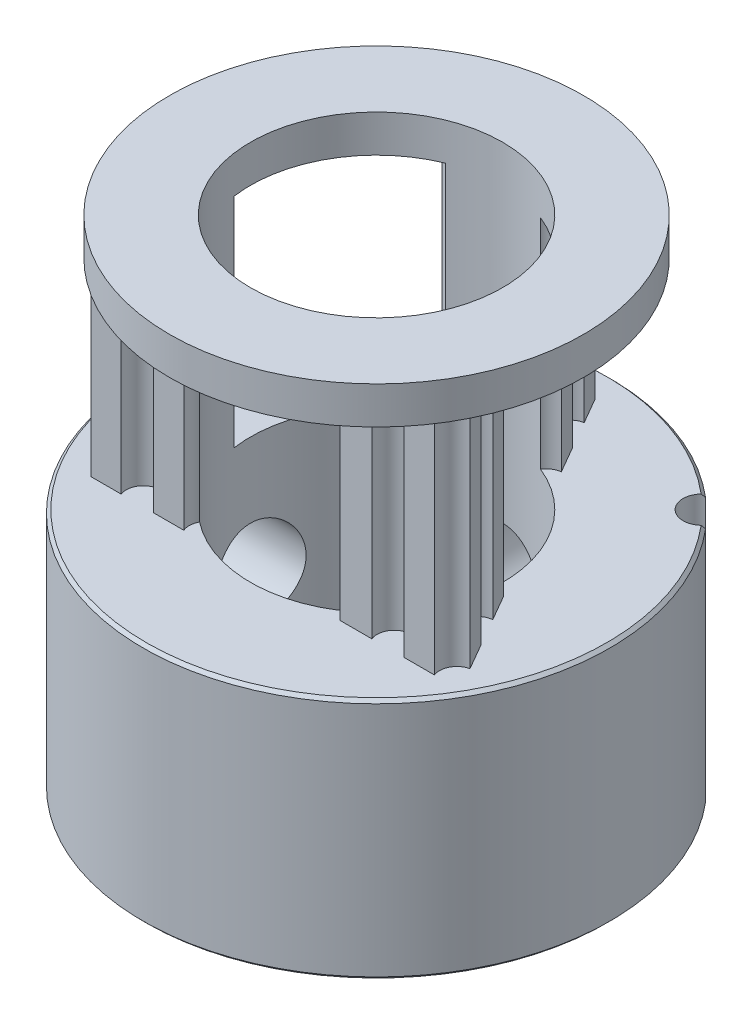
from build123d import *

# Parameters (mm, degrees)
P_IDAT_START            = 7.8
SKICA1_R                = 2.5
P_IDAT_VYSUNUT_M1_DEPTH = 7
SKICA2_R                = 3.5
SKICA2_R_2              = 2.5
P_IDAT_VYSUNUT_M2_DEPTH = 7.8
SKICA3_R                = 3.5
SKICA3_R_2              = 2.5
P_IDAT_VYSUNUT_M3_DEPTH = 1.2
SKICA5_R                = 7.5
SKICA5_R_2              = 3.5
P_IDAT_VYSUNUT_M4_DEPTH = 1.2
SKICA6_R                = 7.5
SKICA6_R_2              = 3.5
P_IDAT_VYSUNUT_M5_DEPTH = 7.8
ZKOSEN_1_SIZE           = 0.1
ZKOSEN_2_SIZE           = 0.1
ZKOSEN_3_SIZE           = 0.1
SKETCH8_OUTSIDE_W       = 22.314
SKETCH8_OUTSIDE_H       = 22.314
SKETCH8_OUTSIDE_R       = 6.65
CUT_EXTRUDE2_DEPTH      = 5
SKETCH19_R              = 1.5
CUT_EXTRUDE6_DEPTH      = 5
SKETCH20_R              = 1.5
CUT_EXTRUDE7_DEPTH      = 5
SKETCH7_R               = 4.05
CUT_EXTRUDE9_DEPTH      = 20
SKETCH27_R              = 7.4
CUT_EXTRUDE12_DEPTH     = 7
BOSS_EXTRUDE2_DEPTH     = 7.1
SKETCH28_R              = 4.05
CUT_EXTRUDE13_DEPTH     = 30
SKETCH30_R              = 0.617994848
CUT_EXTRUDE15_DEPTH     = 30


with BuildPart() as part:
    # Skica1 → Přidat vysunutím1 (new body)
    with BuildSketch(Plane(origin=(0, 0, 0), x_dir=(1, 0, 0), z_dir=(0, 1, 0)).offset(P_IDAT_START)):
        with BuildLine():
            ThreePointArc((-5.730143195, 1.098270155), (-5.09645097, 1.530497044), (-5.387174672, 2.240331989))
            ThreePointArc((-5.387174672, 2.240331989), (-5.468060657, 2.292707421), (-5.540463547, 2.356296335))
            ThreePointArc((-5.540463547, 2.356296335), (-5.573874331, 2.399596558), (-5.596043873, 2.44959357))
            ThreePointArc((-5.596043873, 2.44959357), (-5.50369925, 2.650567912), (-5.404139771, 2.848067596))
            ThreePointArc((-5.404139771, 2.848067596), (-5.351227535, 2.86190541), (-5.296542742, 2.862779021))
            ThreePointArc((-5.296542742, 2.862779021), (-5.201685094, 2.845815675), (-5.110305882, 2.815228615))
            ThreePointArc((-5.110305882, 2.815228615), (-4.374063308, 3.030479148), (-4.431206919, 3.795410862))
            ThreePointArc((-4.431206919, 3.795410862), (-4.491949163, 3.870218002), (-4.541158349, 3.953068377))
            ThreePointArc((-4.541158349, 3.953068377), (-4.559553388, 4.004573836), (-4.565187949, 4.058974585))
            ThreePointArc((-4.565187949, 4.058974585), (-4.415258506, 4.221576484), (-4.259541056, 4.378644275))
            ThreePointArc((-4.259541056, 4.378644275), (-4.204942409, 4.375454038), (-4.15266412, 4.359386362))
            ThreePointArc((-4.15266412, 4.359386362), (-4.067691098, 4.313940635), (-3.990236225, 4.256612884))
            ThreePointArc((-3.990236225, 4.256612884), (-3.223511854, 4.233816838), (-3.041481758, 4.978968476))
            ThreePointArc((-3.041481758, 4.978968476), (-3.076134388, 5.06888468), (-3.097332931, 5.162886543))
            ThreePointArc((-3.097332931, 5.162886543), (-3.09891159, 5.217555525), (-3.08745962, 5.271034888))
            ThreePointArc((-3.08745962, 5.271034888), (-2.894621497, 5.379347737), (-2.697988784, 5.480608745))
            ThreePointArc((-2.697988784, 5.480608745), (-2.647048223, 5.460702739), (-2.6022938, 5.429266591))
            ThreePointArc((-2.6022938, 5.429266591), (-2.535523156, 5.359787029), (-2.479574443, 5.281330225))
            ThreePointArc((-2.479574443, 5.281330225), (-1.7574206, 5.022719037), (-1.354035171, 5.675149965))
            ThreePointArc((-1.354035171, 5.675149965), (-1.359206146, 5.771373608), (-1.350318985, 5.867325402))
            ThreePointArc((-1.350318985, 5.867325402), (-1.334926735, 5.919806527), (-1.307509232, 5.967129569))
            ThreePointArc((-1.307509232, 5.967129569), (-1.090638767, 6.010550954), (-0.872338572, 6.046093045))
            ThreePointArc((-0.872338572, 6.046093045), (-0.830042514, 6.01141981), (-0.797192832, 5.967692379))
            ThreePointArc((-0.797192832, 5.967692379), (-0.755160541, 5.880980125), (-0.726194639, 5.789074167))
            ThreePointArc((-0.726194639, 5.789074167), (-0.119300773, 5.319962501), (0.465953812, 5.815808234))
            ThreePointArc((0.465953812, 5.815808234), (0.490770664, 5.908920276), (0.528873591, 5.997429571))
            ThreePointArc((0.528873591, 5.997429571), (0.55973005, 6.04258562), (0.600429269, 6.079120034))
            ThreePointArc((0.600429269, 6.079120034), (0.820103284, 6.053399565), (1.038702217, 6.019743632))
            ThreePointArc((1.038702217, 6.019743632), (1.06821354, 5.973697225), (1.085942924, 5.921958857))
            ThreePointArc((1.085942924, 5.921958857), (1.099122448, 5.826501911), (1.098270155, 5.730143195))
            ThreePointArc((1.098270155, 5.730143195), (1.530497044, 5.09645097), (2.240331989, 5.387174672))
            ThreePointArc((2.240331989, 5.387174672), (2.292707421, 5.468060657), (2.356296335, 5.540463547))
            ThreePointArc((2.356296335, 5.540463547), (2.399596558, 5.573874331), (2.44959357, 5.596043873))
            ThreePointArc((2.44959357, 5.596043873), (2.650567912, 5.50369925), (2.848067596, 5.404139771))
            ThreePointArc((2.848067596, 5.404139771), (2.86190541, 5.351227535), (2.862779021, 5.296542742))
            ThreePointArc((2.862779021, 5.296542742), (2.845815675, 5.201685094), (2.815228615, 5.110305882))
            ThreePointArc((2.815228615, 5.110305882), (3.030479148, 4.374063308), (3.795410862, 4.431206919))
            ThreePointArc((3.795410862, 4.431206919), (3.870218002, 4.491949163), (3.953068377, 4.541158349))
            ThreePointArc((3.953068377, 4.541158349), (4.004573836, 4.559553388), (4.058974585, 4.565187949))
            ThreePointArc((4.058974585, 4.565187949), (4.221576484, 4.415258506), (4.378644275, 4.259541056))
            ThreePointArc((4.378644275, 4.259541056), (4.375454038, 4.204942409), (4.359386362, 4.15266412))
            ThreePointArc((4.359386362, 4.15266412), (4.313940635, 4.067691098), (4.256612884, 3.990236225))
            ThreePointArc((4.256612884, 3.990236225), (4.233816838, 3.223511854), (4.978968476, 3.041481758))
            ThreePointArc((4.978968476, 3.041481758), (5.06888468, 3.076134388), (5.162886543, 3.097332931))
            ThreePointArc((5.162886543, 3.097332931), (5.217555525, 3.09891159), (5.271034888, 3.08745962))
            ThreePointArc((5.271034888, 3.08745962), (5.379347737, 2.894621497), (5.480608745, 2.697988784))
            ThreePointArc((5.480608745, 2.697988784), (5.460702739, 2.647048223), (5.429266591, 2.6022938))
            ThreePointArc((5.429266591, 2.6022938), (5.359787029, 2.535523156), (5.281330225, 2.479574443))
            ThreePointArc((5.281330225, 2.479574443), (5.022719037, 1.7574206), (5.675149965, 1.354035171))
            ThreePointArc((5.675149965, 1.354035171), (5.771373608, 1.359206146), (5.867325402, 1.350318985))
            ThreePointArc((5.867325402, 1.350318985), (5.919806527, 1.334926735), (5.967129569, 1.307509232))
            ThreePointArc((5.967129569, 1.307509232), (6.010550954, 1.090638767), (6.046093045, 0.872338572))
            ThreePointArc((6.046093045, 0.872338572), (6.01141981, 0.830042514), (5.967692379, 0.797192832))
            ThreePointArc((5.967692379, 0.797192832), (5.880980125, 0.755160541), (5.789074167, 0.726194639))
            ThreePointArc((5.789074167, 0.726194639), (5.319962501, 0.119300773), (5.815808234, -0.465953812))
            ThreePointArc((5.815808234, -0.465953812), (5.908920276, -0.490770664), (5.997429571, -0.528873591))
            ThreePointArc((5.997429571, -0.528873591), (6.04258562, -0.55973005), (6.079120034, -0.600429269))
            ThreePointArc((6.079120034, -0.600429269), (6.053399565, -0.820103284), (6.019743632, -1.038702217))
            ThreePointArc((6.019743632, -1.038702217), (5.973697225, -1.06821354), (5.921958857, -1.085942924))
            ThreePointArc((5.921958857, -1.085942924), (5.826501911, -1.099122448), (5.730143195, -1.098270155))
            ThreePointArc((5.730143195, -1.098270155), (5.09645097, -1.530497044), (5.387174672, -2.240331989))
            ThreePointArc((5.387174672, -2.240331989), (5.468060657, -2.292707421), (5.540463547, -2.356296335))
            ThreePointArc((5.540463547, -2.356296335), (5.573874331, -2.399596558), (5.596043873, -2.44959357))
            ThreePointArc((5.596043873, -2.44959357), (5.50369925, -2.650567911), (5.404139771, -2.848067596))
            ThreePointArc((5.404139771, -2.848067596), (5.351227535, -2.86190541), (5.296542742, -2.862779021))
            ThreePointArc((5.296542742, -2.862779021), (5.201685094, -2.845815675), (5.110305882, -2.815228615))
            ThreePointArc((5.110305882, -2.815228615), (4.374063308, -3.030479148), (4.431206919, -3.795410862))
            ThreePointArc((4.431206919, -3.795410862), (4.491949163, -3.870218002), (4.541158349, -3.953068377))
            ThreePointArc((4.541158349, -3.953068377), (4.559553388, -4.004573836), (4.565187949, -4.058974585))
            ThreePointArc((4.565187949, -4.058974585), (4.415258506, -4.221576484), (4.259541056, -4.378644275))
            ThreePointArc((4.259541056, -4.378644275), (4.204942409, -4.375454038), (4.15266412, -4.359386362))
            ThreePointArc((4.15266412, -4.359386362), (4.067691098, -4.313940635), (3.990236225, -4.256612884))
            ThreePointArc((3.990236225, -4.256612884), (3.223511854, -4.233816838), (3.041481758, -4.978968476))
            ThreePointArc((3.041481758, -4.978968476), (3.076134388, -5.06888468), (3.097332931, -5.162886543))
            ThreePointArc((3.097332931, -5.162886543), (3.09891159, -5.217555525), (3.08745962, -5.271034888))
            ThreePointArc((3.08745962, -5.271034888), (2.894621497, -5.379347737), (2.697988784, -5.480608745))
            ThreePointArc((2.697988784, -5.480608745), (2.647048223, -5.460702739), (2.6022938, -5.429266591))
            ThreePointArc((2.6022938, -5.429266591), (2.535523156, -5.359787029), (2.479574443, -5.281330225))
            ThreePointArc((2.479574443, -5.281330225), (1.7574206, -5.022719037), (1.354035171, -5.675149965))
            ThreePointArc((1.354035171, -5.675149965), (1.359206146, -5.771373608), (1.350318985, -5.867325402))
            ThreePointArc((1.350318985, -5.867325402), (1.334926735, -5.919806527), (1.307509232, -5.967129569))
            ThreePointArc((1.307509232, -5.967129569), (1.090638767, -6.010550954), (0.872338572, -6.046093045))
            ThreePointArc((0.872338572, -6.046093045), (0.830042514, -6.01141981), (0.797192832, -5.967692379))
            ThreePointArc((0.797192832, -5.967692379), (0.755160541, -5.880980125), (0.726194639, -5.789074167))
            ThreePointArc((0.726194639, -5.789074167), (0.119300773, -5.319962501), (-0.465953812, -5.815808234))
            ThreePointArc((-0.465953812, -5.815808234), (-0.490770664, -5.908920276), (-0.528873591, -5.997429571))
            ThreePointArc((-0.528873591, -5.997429571), (-0.55973005, -6.04258562), (-0.600429269, -6.079120034))
            ThreePointArc((-0.600429269, -6.079120034), (-0.820103284, -6.053399565), (-1.038702217, -6.019743632))
            ThreePointArc((-1.038702217, -6.019743632), (-1.06821354, -5.973697225), (-1.085942924, -5.921958857))
            ThreePointArc((-1.085942924, -5.921958857), (-1.099122448, -5.826501911), (-1.098270155, -5.730143195))
            ThreePointArc((-1.098270155, -5.730143195), (-1.530497044, -5.09645097), (-2.240331989, -5.387174672))
            ThreePointArc((-2.240331989, -5.387174672), (-2.292707421, -5.468060657), (-2.356296335, -5.540463547))
            ThreePointArc((-2.356296335, -5.540463547), (-2.399596558, -5.573874331), (-2.44959357, -5.596043873))
            ThreePointArc((-2.44959357, -5.596043873), (-2.650567912, -5.50369925), (-2.848067596, -5.404139771))
            ThreePointArc((-2.848067596, -5.404139771), (-2.86190541, -5.351227535), (-2.862779021, -5.296542742))
            ThreePointArc((-2.862779021, -5.296542742), (-2.845815675, -5.201685094), (-2.815228615, -5.110305882))
            ThreePointArc((-2.815228615, -5.110305882), (-3.030479148, -4.374063308), (-3.795410862, -4.431206919))
            ThreePointArc((-3.795410862, -4.431206919), (-3.870218002, -4.491949163), (-3.953068377, -4.541158349))
            ThreePointArc((-3.953068377, -4.541158349), (-4.004573836, -4.559553388), (-4.058974585, -4.565187949))
            ThreePointArc((-4.058974585, -4.565187949), (-4.221576484, -4.415258506), (-4.378644275, -4.259541056))
            ThreePointArc((-4.378644275, -4.259541056), (-4.375454038, -4.204942409), (-4.359386362, -4.15266412))
            ThreePointArc((-4.359386362, -4.15266412), (-4.313940635, -4.067691098), (-4.256612884, -3.990236225))
            ThreePointArc((-4.256612884, -3.990236225), (-4.233816838, -3.223511854), (-4.978968476, -3.041481758))
            ThreePointArc((-4.978968476, -3.041481758), (-5.06888468, -3.076134388), (-5.162886543, -3.097332931))
            ThreePointArc((-5.162886543, -3.097332931), (-5.217555525, -3.09891159), (-5.271034888, -3.08745962))
            ThreePointArc((-5.271034888, -3.08745962), (-5.379347737, -2.894621497), (-5.480608745, -2.697988784))
            ThreePointArc((-5.480608745, -2.697988784), (-5.460702739, -2.647048223), (-5.429266591, -2.6022938))
            ThreePointArc((-5.429266591, -2.6022938), (-5.359787029, -2.535523156), (-5.281330225, -2.479574443))
            ThreePointArc((-5.281330225, -2.479574443), (-5.022719037, -1.7574206), (-5.675149965, -1.354035171))
            ThreePointArc((-5.675149965, -1.354035171), (-5.771373608, -1.359206146), (-5.867325402, -1.350318985))
            ThreePointArc((-5.867325402, -1.350318985), (-5.919806527, -1.334926735), (-5.967129569, -1.307509232))
            ThreePointArc((-5.967129569, -1.307509232), (-6.010550954, -1.090638767), (-6.046093045, -0.872338572))
            ThreePointArc((-6.046093045, -0.872338572), (-6.01141981, -0.830042514), (-5.967692379, -0.797192832))
            ThreePointArc((-5.967692379, -0.797192832), (-5.880980125, -0.755160541), (-5.789074167, -0.726194639))
            ThreePointArc((-5.789074167, -0.726194639), (-5.319962501, -0.119300773), (-5.815808234, 0.465953812))
            ThreePointArc((-5.815808234, 0.465953812), (-5.908920276, 0.490770664), (-5.997429571, 0.528873591))
            ThreePointArc((-5.997429571, 0.528873591), (-6.04258562, 0.55973005), (-6.079120034, 0.600429269))
            ThreePointArc((-6.079120034, 0.600429269), (-6.053399565, 0.820103284), (-6.019743632, 1.038702217))
            ThreePointArc((-6.019743632, 1.038702217), (-5.973697225, 1.06821354), (-5.921958857, 1.085942924))
            ThreePointArc((-5.921958857, 1.085942924), (-5.826501911, 1.099122448), (-5.730143195, 1.098270155))
        make_face()
        Circle(SKICA1_R, mode=Mode.SUBTRACT)
    extrude(amount=P_IDAT_VYSUNUT_M1_DEPTH)

    # Skica2 → Přidat vysunutím2 (add)
    with BuildSketch(Plane.XZ.offset(-7.8)):
        Circle(SKICA2_R)
        Circle(SKICA2_R_2, mode=Mode.SUBTRACT)
    extrude(amount=P_IDAT_VYSUNUT_M2_DEPTH)

    # Skica3 → Přidat vysunutím3 (add)
    with BuildSketch(Plane(origin=(0, 14.8, 0), x_dir=(1, 0, 0), z_dir=(0, 1, 0))):
        Circle(SKICA3_R)
        Circle(SKICA3_R_2, mode=Mode.SUBTRACT)
    extrude(amount=P_IDAT_VYSUNUT_M3_DEPTH)

    # Zkosení2
    zkosen_2_edges = [part.edges().sort_by_distance(p)[0] for p in [
        (-2.5, 0, 0),
        (-2.5, 16, 0),
    ]]
    chamfer(zkosen_2_edges, length=ZKOSEN_2_SIZE)


with BuildPart() as body_2:
    # Skica5 → Přidat vysunutím4 (new body)
    with BuildSketch(Plane(origin=(0, 16, 0), x_dir=(1, 0, 0), z_dir=(0, 1, 0))):
        Circle(SKICA5_R)
        Circle(SKICA5_R_2, mode=Mode.SUBTRACT)
    extrude(amount=-P_IDAT_VYSUNUT_M4_DEPTH)

    # Zkosení1
    zkosen_1_edges = [body_2.edges().sort_by_distance(p)[0] for p in [
        (-7.5, 16, 0),
        (-7.5, 14.8, 0),
    ]]
    chamfer(zkosen_1_edges, length=ZKOSEN_1_SIZE)

    # Sketch8 outside → Cut-Extrude2 (cut)
    with BuildSketch(Plane(origin=(0, 16, 0), x_dir=(1, 0, 0), z_dir=(0, 1, 0))):
        Rectangle(SKETCH8_OUTSIDE_W, SKETCH8_OUTSIDE_H)
        Circle(SKETCH8_OUTSIDE_R, mode=Mode.SUBTRACT)
    extrude(amount=-CUT_EXTRUDE2_DEPTH, mode=Mode.SUBTRACT)


with BuildPart() as body_3:
    # Skica6 → Přidat vysunutím5 (new body)
    with BuildSketch(Plane.XZ):
        Circle(SKICA6_R)
        Circle(SKICA6_R_2, mode=Mode.SUBTRACT)
    extrude(amount=-P_IDAT_VYSUNUT_M5_DEPTH)

    # Zkosení3
    zkosen_3_edges = [body_3.edges().sort_by_distance(p)[0] for p in [
        (-7.5, 0, 0),
        (-7.5, 7.8, 0),
    ]]
    chamfer(zkosen_3_edges, length=ZKOSEN_3_SIZE)

    # Sketch19 → Cut-Extrude6 (cut)
    with BuildSketch(Plane(origin=(0, 0, -7.5), x_dir=(-1, 0, 0), z_dir=(0, 0, -1))):
        with Locations((0, 3.9)):
            Circle(SKETCH19_R)
    extrude(amount=-CUT_EXTRUDE6_DEPTH, mode=Mode.SUBTRACT)

    # Sketch20 → Cut-Extrude7 (cut)
    with BuildSketch(Plane.ZY.offset(7.5)):
        with Locations((0, 3.9)):
            Circle(SKETCH20_R)
    extrude(amount=-CUT_EXTRUDE7_DEPTH, mode=Mode.SUBTRACT)


with BuildPart() as cut_extrude9_tool:
    # Sketch7 → Cut-Extrude9 (new body)
    with BuildSketch(Plane.XZ):
        Circle(SKETCH7_R)
    extrude(amount=-CUT_EXTRUDE9_DEPTH)


with BuildPart() as part_1:
    add(part.part)

    # Cut-Extrude9: cut by cut_extrude9_tool
    add(cut_extrude9_tool.part, mode=Mode.SUBTRACT)

    # Sketch27 → Cut-Extrude12 (cut)
    with BuildSketch(Plane(origin=(0, 7.8, 0), x_dir=(1, 0, 0), z_dir=(0, 1, 0))):
        Circle(SKETCH27_R)
    extrude(amount=CUT_EXTRUDE12_DEPTH, mode=Mode.SUBTRACT)


with BuildPart() as body_2_1:
    add(body_2.part)

    # Cut-Extrude9: cut by cut_extrude9_tool
    add(cut_extrude9_tool.part, mode=Mode.SUBTRACT)



with BuildPart() as body_3_1:
    add(body_3.part)

    # Cut-Extrude9: cut by cut_extrude9_tool
    add(cut_extrude9_tool.part, mode=Mode.SUBTRACT)


with BuildPart() as body_2_2:
    add(body_2_1.part)

    add(body_3_1.part)  # Boss-Extrude2 merges body 3
    # Sketch25 → Boss-Extrude2 (add)
    with BuildSketch(Plane(origin=(0, 7.8, 0), x_dir=(1, 0, 0), z_dir=(0, 1, 0))):
        with BuildLine():
            Line((-0.717938034, 6.096494849), (-0.907057907, 5.768929619))
            ThreePointArc((-0.907057907, 5.768929619), (-0.50810169, 4.942474166), (-1.423311217, 4.874752658))
            Line((-1.423311217, 4.874752658), (-1.918483232, 4.017089569))
            ThreePointArc((-1.918483232, 4.017089569), (-1.536908146, 3.193503192), (-2.440942413, 3.112163722))
            Line((-2.440942413, 3.112163722), (-2.91615597, 2.289069697))
            ThreePointArc((-2.91615597, 2.289069697), (-2.524743358, 1.463789867), (-3.435162962, 1.390123218))
            Line((-3.435162962, 1.390123218), (-3.927672168, 0.53707225))
            ThreePointArc((-3.927672168, 0.53707225), (-3.52415558, -0.290042476), (-4.442216238, -0.354144223))
            Line((-4.442216238, -0.354144223), (-4.911986074, -1.167809446))
            ThreePointArc((-4.911986074, -1.167809446), (-4.535840997, -1.990382794), (-5.436282951, -2.075918275))
            Line((-5.436282951, -2.075918275), (-5.898945462, -2.877273251))
            ThreePointArc((-5.898945462, -2.877273251), (-5.507068696, -3.176777484), (-5.508386199, -3.67))
            Line((-5.508386199, -3.67), (-4.536814361, -3.67))
            ThreePointArc((-4.536814361, -3.67), (-4.017748656, -2.91854188), (-3.49868295, -3.67))
            Line((-3.49868295, -3.67), (-2.520776964, -3.67))
            ThreePointArc((-2.520776964, -3.67), (-2.009979522, -2.897949376), (-1.499182081, -3.67))
            Line((-1.499182081, -3.67), (-0.513007831, -3.67))
            ThreePointArc((-0.513007831, -3.67), (-0.002210389, -2.897949376), (0.508587053, -3.67))
            Line((0.508587053, -3.67), (1.474168799, -3.67))
            ThreePointArc((1.474168799, -3.67), (1.98496624, -2.897949376), (2.495763682, -3.67))
            Line((2.495763682, -3.67), (3.518869287, -3.67))
            ThreePointArc((3.518869287, -3.67), (4.033920381, -2.908245628), (4.548971475, -3.67))
            Line((4.548971475, -3.67), (5.530558251, -3.67))
            ThreePointArc((5.530558251, -3.67), (5.556358411, -3.205925047), (5.92604395, -2.92420921))
            Line((5.92604395, -2.92420921), (5.4337836, -2.071589272))
            ThreePointArc((5.4337836, -2.071589272), (4.505290561, -2.021283953), (4.925971396, -1.192032735))
            Line((4.925971396, -1.192032735), (4.445945351, -0.360603235))
            ThreePointArc((4.445945351, -0.360603235), (3.569336636, -0.24921119), (3.911172652, 0.565650249))
            Line((3.911172652, 0.565650249), (3.418477875, 1.419022635))
            ThreePointArc((3.418477875, 1.419022635), (2.483630084, 1.460464645), (2.915164146, 2.290787587))
            Line((2.915164146, 2.290787587), (2.427366725, 3.135677503))
            ThreePointArc((2.427366725, 3.135677503), (1.503804697, 3.192615402), (1.916276044, 4.02091253))
            Line((1.916276044, 4.02091253), (1.436397938, 4.852085792))
            ThreePointArc((1.436397938, 4.852085792), (0.532106306, 4.93312138), (0.914073244, 5.7567787))
            Line((0.914073244, 5.7567787), (0.432060736, 6.591648854))
            ThreePointArc((0.432060736, 6.591648854), (0, 6.385), (-0.432060736, 6.591648854))
            Line((-0.432060736, 6.591648854), (-0.717938034, 6.096494849))
        make_face()
    extrude(amount=BOSS_EXTRUDE2_DEPTH)

    # Sketch28 → Cut-Extrude13 (cut)
    with BuildSketch(Plane(origin=(0, 16, 0), x_dir=(1, 0, 0), z_dir=(0, 1, 0))):
        Circle(SKETCH28_R)
    extrude(amount=-CUT_EXTRUDE13_DEPTH, mode=Mode.SUBTRACT)

    # Sketch30 → Cut-Extrude15 (cut)
    with BuildSketch(Plane.XZ):
        with Locations((5.232590181, -5.232590181)):
            Circle(SKETCH30_R)
    extrude(amount=-CUT_EXTRUDE15_DEPTH, mode=Mode.SUBTRACT)


solid = body_2_2.part
